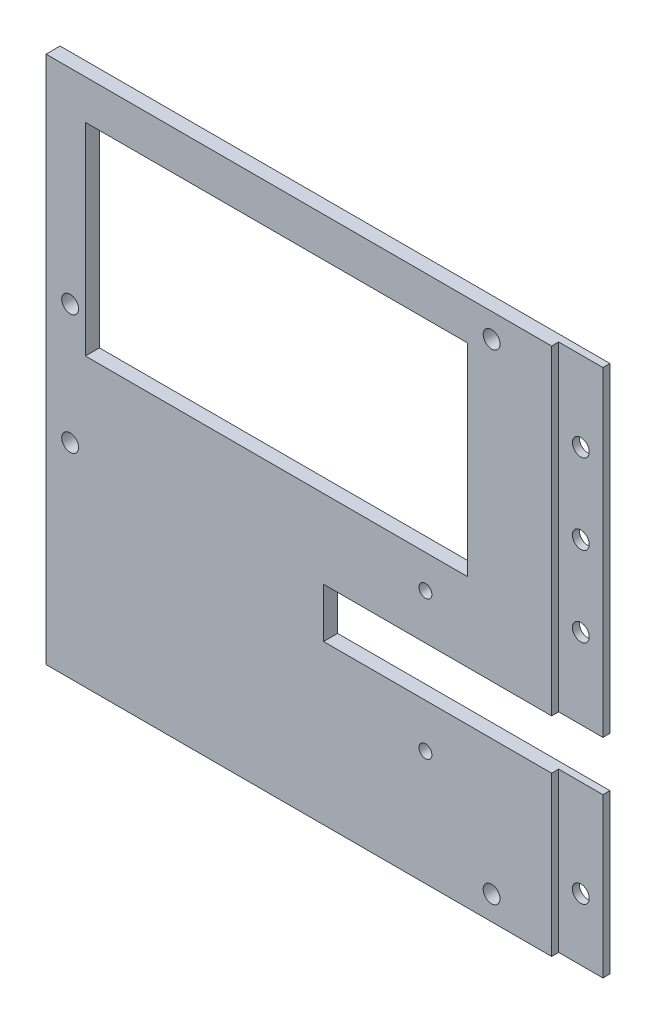
from build123d import *

# Parameters (mm, degrees)
SKETCH2_W           = 124.173
SKETCH2_H           = 119.38
BOSS_EXTRUDE1_DEPTH = 3.175
SKETCH4_R           = 1.905
SKETCH4_R_2         = 1.46
SKETCH4_W           = 86.3
SKETCH4_H           = 45.7
SKETCH4_W_2         = 61.5
SKETCH4_H_2         = 11.2
CUT_EXTRUDE1_DEPTH  = 14.175
SKETCH10_W          = 1.59
SKETCH10_H          = 120
CUT_EXTRUDE3_DEPTH  = 10
SKETCH11_R          = 1.905
CUT_EXTRUDE4_DEPTH  = 10


with BuildPart() as part:
    # Sketch2 → Boss-Extrude1 (new body)
    with BuildSketch(Plane.XY):
        with Locations((40.767155738, -50.87039032)):
            Rectangle(SKETCH2_W, SKETCH2_H)
    extrude(amount=BOSS_EXTRUDE1_DEPTH)

    # Sketch4 → Cut-Extrude1 (cut)
    with BuildSketch(Plane.XY):
        with Locations((-15.867344262, -37.32039032)):
            Circle(SKETCH4_R)
        with Locations((-15.867344262, -64.42239032)):
            Circle(SKETCH4_R)
        with Locations((79.302655738, 3.36760968)):
            Circle(SKETCH4_R)
        with Locations((79.300655738, -105.10839032)):
            Circle(SKETCH4_R)
        with Locations((64.353655738, -53.29939032)):
            Circle(SKETCH4_R_2)
        with Locations((64.353655738, -84.64939032)):
            Circle(SKETCH4_R_2)
        with Locations((30.720655738, -22.92039032)):
            Rectangle(SKETCH4_W, SKETCH4_H)
        with Locations((72.103655738, -69.11339032)):
            Rectangle(SKETCH4_W_2, SKETCH4_H_2)
    extrude(amount=CUT_EXTRUDE1_DEPTH, mode=Mode.SUBTRACT)

    # Sketch10 → Cut-Extrude3 (cut)
    with BuildSketch(Plane(origin=(102.853655738, 0, 0), x_dir=(0, 0, -1), z_dir=(1, 0, 0))):
        with Locations((-2.380000064, -51.180389625)):
            Rectangle(SKETCH10_W, SKETCH10_H)
    extrude(amount=-CUT_EXTRUDE3_DEPTH, mode=Mode.SUBTRACT)

    # Sketch11 → Cut-Extrude4 (cut)
    with BuildSketch(Plane.XY.offset(3.175)):
        with Locations((97.853655738, -9.262889625)):
            Circle(SKETCH11_R)
        with Locations((97.853655738, -27.345389625)):
            Circle(SKETCH11_R)
        with Locations((97.853655738, -45.43089032)):
            Circle(SKETCH11_R)
        with Locations((97.853655738, -96.56039032)):
            Circle(SKETCH11_R)
    extrude(amount=-CUT_EXTRUDE4_DEPTH, mode=Mode.SUBTRACT)


solid = part.part
